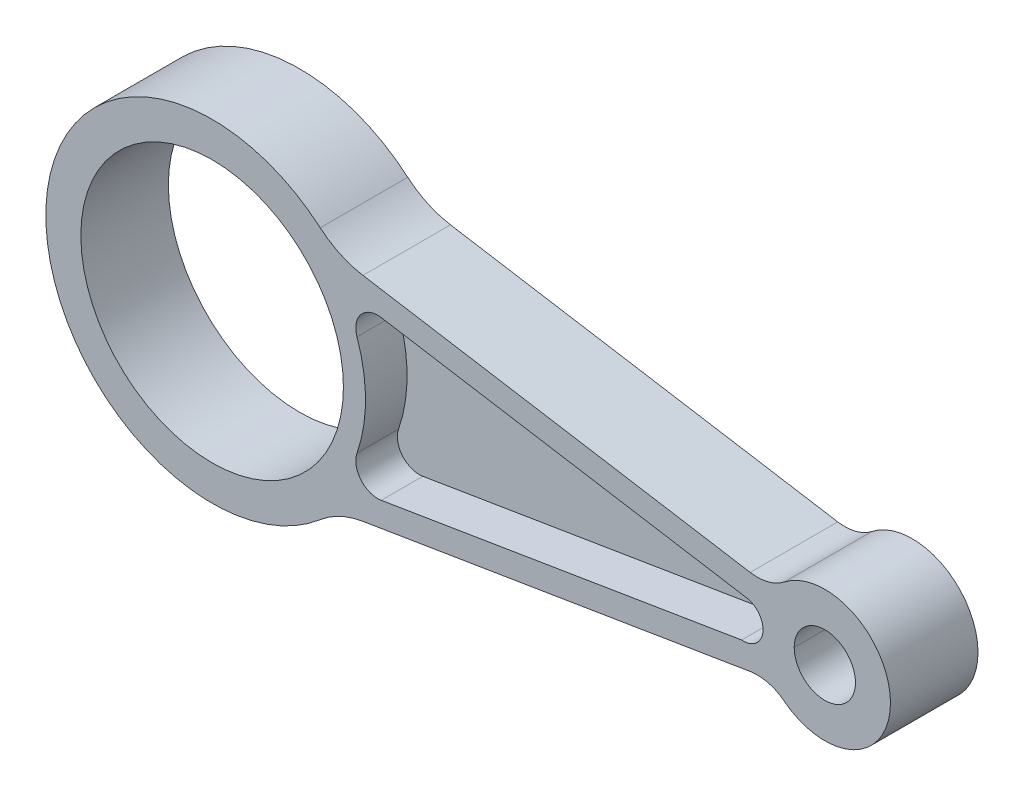
from build123d import *

# Parameters (mm, degrees)
SKETCH1_R           = 30
SKETCH1_R_2         = 7
BOSS_EXTRUDE1_DEPTH = 10
FILLET1_R           = 20
FILLET2_R           = 10
CUT_EXTRUDE1_DEPTH  = 9.5


with BuildPart() as part:
    # Sketch1 → Boss-Extrude1 (new body, symmetric)
    with BuildSketch(Plane.XY):
        with BuildLine():
            Line((28.309347234, -25.349178669), (127.980959562, -8.974556643))
            ThreePointArc((127.980959562, -8.974556643), (155, 0), (127.980959562, 8.974556643))
            Line((127.980959562, 8.974556643), (28.309347234, 25.349178669))
            ThreePointArc((28.309347234, 25.349178669), (-38, 0), (28.309347234, -25.349178669))
        make_face()
        Circle(SKETCH1_R, mode=Mode.SUBTRACT)
        with Locations((140, 0)):
            Circle(SKETCH1_R_2, mode=Mode.SUBTRACT)
    extrude(amount=BOSS_EXTRUDE1_DEPTH, both=True)

    # Fillet1
    fillet1_edges = [part.edges().sort_by_distance(p)[0] for p in [
        (28.309347234, 25.349178669, 0),
        (28.309347234, -25.349178669, 0),
    ]]
    fillet(fillet1_edges, radius=FILLET1_R)

    # Fillet2
    fillet2_edges = [part.edges().sort_by_distance(p)[0] for p in [
        (127.980959562, 8.974556643, 0),
        (127.980959562, -8.974556643, 0),
    ]]
    fillet(fillet2_edges, radius=FILLET2_R)

    # Sketch2 → Cut-Extrude1 (cut)
    with BuildSketch(Plane.XY.offset(10)):
        with BuildLine():
            Line((38.638691874, 18.07848713), (121.848393563, 4.408321852))
            ThreePointArc((121.848393563, 4.408321852), (125.854189802, -0.497633455), (120.986555874, -4.549909473))
            Line((120.986555874, -4.549909473), (38.638691874, -18.07848713))
            ThreePointArc((38.638691874, -18.07848713), (34.002624892, -16.364178365), (33.10514216, -11.503468916))
            ThreePointArc((33.10514216, -11.503468916), (35.046829165, 0), (33.10514216, 11.503468916))
            ThreePointArc((33.10514216, 11.503468916), (34.002624892, 16.364178365), (38.638691874, 18.07848713))
        make_face()
    cut_extrude1 = extrude(amount=-CUT_EXTRUDE1_DEPTH, mode=Mode.SUBTRACT)

    # Mirror1: Cut-Extrude1 across plane
    add(cut_extrude1.mirror(Plane.XY), mode=Mode.SUBTRACT)


solid = part.part
